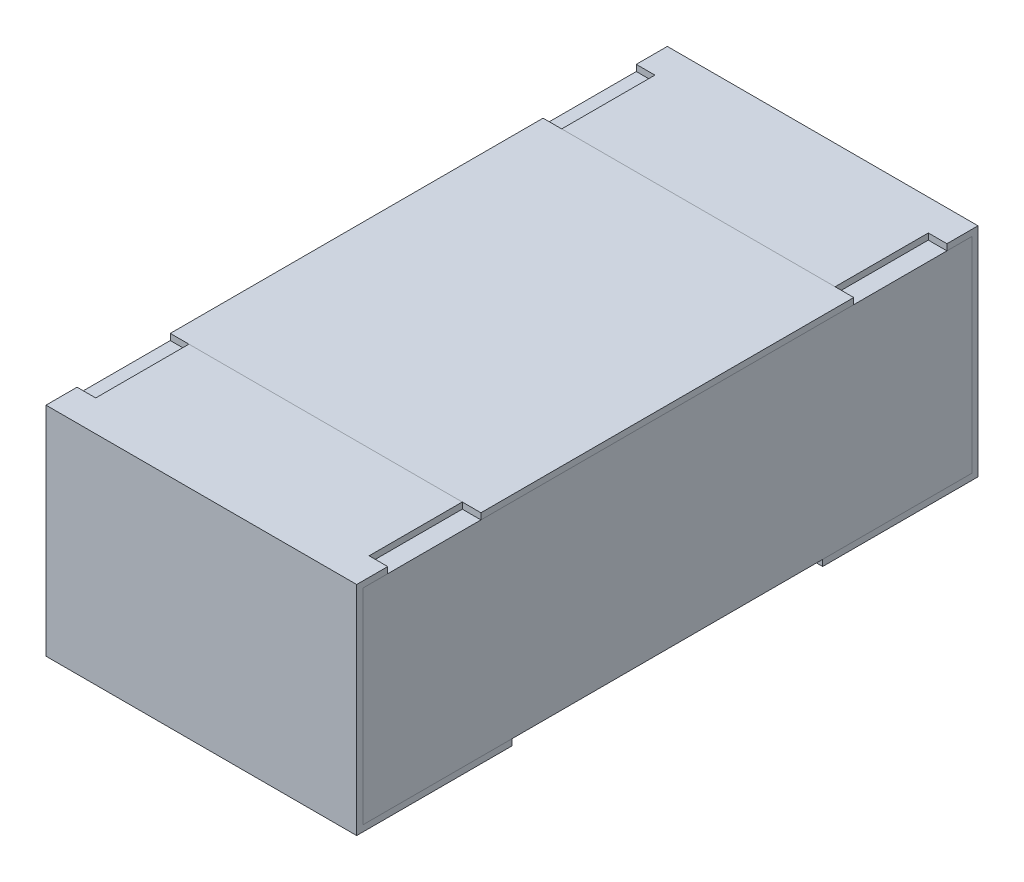
from build123d import *

# Parameters (mm, degrees)
BOSS_EXTRUDE2_DEPTH   = 0.25
BOSS_EXTRUDE2_2_DEPTH = 0.25
BOSS_EXTRUDE3_START   = -0.25
SKETCH5_W             = 0.98
SKETCH5_H             = 0.33
BOSS_EXTRUDE3_DEPTH   = 0.5
SKETCH6_W             = 0.03
SKETCH6_H             = 0.15
CUT_EXTRUDE1_DEPTH    = 0.01
SKETCH7_W             = 0.5
SKETCH7_H             = 0.6
BOSS_EXTRUDE4_DEPTH   = 0.01


with BuildPart() as part:
    # Sketch4 → Boss-Extrude2 (new body, symmetric)
    with BuildSketch(Plane(origin=(0, 0, 0), x_dir=(0, 0, -1), z_dir=(1, 0, 0))):
        Polygon((-0.5, 0.175), (-0.5, -0.175), (-0.25, -0.175), (-0.25, -0.165), (-0.49, -0.165), (-0.49, 0.165), (-0.3, 0.165), (-0.3, 0.175), align=None)
    extrude(amount=BOSS_EXTRUDE2_DEPTH, both=True)


with BuildPart() as body_2:
    # Sketch4 → Boss-Extrude2 2 (new body, symmetric)
    with BuildSketch(Plane(origin=(0, 0, 0), x_dir=(0, 0, -1), z_dir=(1, 0, 0))):
        Polygon((0.3, 0.175), (0.5, 0.175), (0.5, -0.175), (0.25, -0.175), (0.25, -0.165), (0.49, -0.165), (0.49, 0.165), (0.3, 0.165), align=None)
    extrude(amount=BOSS_EXTRUDE2_2_DEPTH, both=True)


with BuildPart() as body_3:
    # Sketch5 → Boss-Extrude3 (new body)
    with BuildSketch(Plane(origin=(0, 0, 0), x_dir=(0, 0, -1), z_dir=(1, 0, 0)).offset(BOSS_EXTRUDE3_START)):
        Rectangle(SKETCH5_W, SKETCH5_H)
    extrude(amount=BOSS_EXTRUDE3_DEPTH)


with BuildPart() as cut_extrude1_tool:
    # Sketch6 → Cut-Extrude1 (new body)
    with BuildSketch(Plane(origin=(0, 0.175, 0), x_dir=(1, 0, 0), z_dir=(0, 1, 0))):
        with Locations((-0.235, 0.375)):
            Rectangle(SKETCH6_W, SKETCH6_H)
        with Locations((0.235, 0.375)):
            Rectangle(SKETCH6_W, SKETCH6_H)
        with Locations((0.235, -0.375)):
            Rectangle(SKETCH6_W, SKETCH6_H)
        with Locations((-0.235, -0.375)):
            Rectangle(SKETCH6_W, SKETCH6_H)
    extrude(amount=-CUT_EXTRUDE1_DEPTH)


with BuildPart() as part_1:
    add(part.part)

    # Cut-Extrude1: cut by cut_extrude1_tool
    add(cut_extrude1_tool.part, mode=Mode.SUBTRACT)


with BuildPart() as body_2_1:
    add(body_2.part)

    # Cut-Extrude1: cut by cut_extrude1_tool
    add(cut_extrude1_tool.part, mode=Mode.SUBTRACT)


with BuildPart() as body_4:
    # Sketch7 → Boss-Extrude4 (new body)
    with BuildSketch(Plane(origin=(0, 0.165, 0), x_dir=(1, 0, 0), z_dir=(0, 1, 0))):
        Rectangle(SKETCH7_W, SKETCH7_H)
    extrude(amount=BOSS_EXTRUDE4_DEPTH)


solid = Compound([body_3.part, part_1.part, body_2_1.part, body_4.part])
